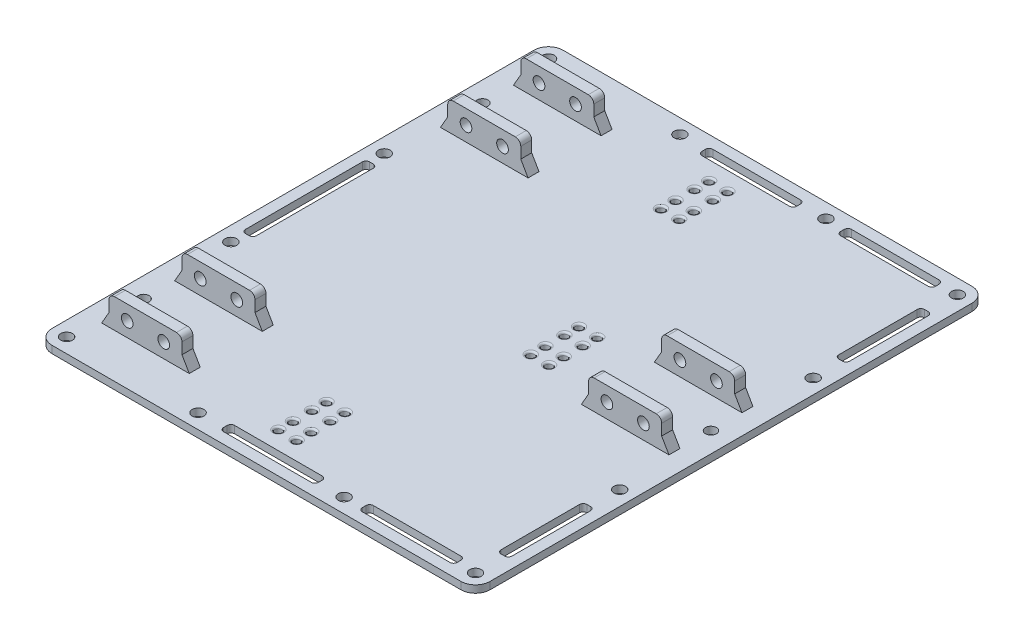
from build123d import *

# Parameters (mm, degrees)
SKETCH1_W           = 120
SKETCH1_H           = 140
BOSS_EXTRUDE1_DEPTH = 2
SKETCH3_W           = 20
SKETCH3_H           = 3
BOSS_EXTRUDE2_DEPTH = 8
SKETCH4_R           = 1.6
CUT_EXTRUDE2_DEPTH  = 142.627716214
SKETCH5_R           = 1.6
CUT_EXTRUDE3_DEPTH  = 93.54188241
FILLET1_R           = 4
SKETCH6_R           = 1
CUT_EXTRUDE4_DEPTH  = 55
CHAMFER1_SIZE       = 2
CHAMFER1_SIZE2      = 3.464101615
CUT_EXTRUDE5_DEPTH  = 93.54188241
FILLET2_R           = 1.5
FILLET3_R           = 0.5
SKETCH9_R           = 1.5
CUT_EXTRUDE6_DEPTH  = 93.54188241


with BuildPart() as part:
    # Sketch1 → Boss-Extrude1 (new body)
    with BuildSketch(Plane(origin=(0, 0, 0), x_dir=(1, 0, 0), z_dir=(0, 1, 0))):
        Rectangle(SKETCH1_W, SKETCH1_H)
    extrude(amount=BOSS_EXTRUDE1_DEPTH)

    # Sketch3 → Boss-Extrude2 (add)
    with BuildSketch(Plane(origin=(0, 2, 0), x_dir=(1, 0, 0), z_dir=(0, 1, 0))):
        with Locations((-42.5, 56.4)):
            Rectangle(SKETCH3_W, SKETCH3_H)
        with Locations((-42.5, 36.4)):
            Rectangle(SKETCH3_W, SKETCH3_H)
        with Locations((-42.5, -36.4)):
            Rectangle(SKETCH3_W, SKETCH3_H)
        with Locations((-42.5, -56.4)):
            Rectangle(SKETCH3_W, SKETCH3_H)
        with Locations((42.5, 10)):
            Rectangle(SKETCH3_W, SKETCH3_H)
        with Locations((42.5, -10)):
            Rectangle(SKETCH3_W, SKETCH3_H)
    extrude(amount=BOSS_EXTRUDE2_DEPTH)

    # Sketch4 → Cut-Extrude2 (cut, through all)
    with BuildSketch(Plane.XY.offset(57.9)):
        with Locations((-47.5, 6)):
            Circle(SKETCH4_R)
        with Locations((-37.5, 6)):
            Circle(SKETCH4_R)
        with Locations((37.5, 6)):
            Circle(SKETCH4_R)
        with Locations((47.5, 6)):
            Circle(SKETCH4_R)
    extrude(amount=-CUT_EXTRUDE2_DEPTH, mode=Mode.SUBTRACT)

    # Sketch5 → Cut-Extrude3 (cut, through all)
    with BuildSketch(Plane(origin=(0, 2, 0), x_dir=(1, 0, 0), z_dir=(0, 1, 0))):
        with Locations((-56, -66)):
            Circle(SKETCH5_R)
        with Locations((56, -66)):
            Circle(SKETCH5_R)
        with Locations((56, 66)):
            Circle(SKETCH5_R)
        with Locations((-56, 66)):
            Circle(SKETCH5_R)
        with Locations((-56, -21)):
            Circle(SKETCH5_R)
        with Locations((-56, 21)):
            Circle(SKETCH5_R)
        with Locations((-20, -66)):
            Circle(SKETCH5_R)
        with Locations((-20, 66)):
            Circle(SKETCH5_R)
        with Locations((20, -66)):
            Circle(SKETCH5_R)
        with Locations((20, 66)):
            Circle(SKETCH5_R)
        with Locations((56, -26.5)):
            Circle(SKETCH5_R)
        with Locations((56, 26.5)):
            Circle(SKETCH5_R)
    extrude(amount=-CUT_EXTRUDE3_DEPTH, mode=Mode.SUBTRACT)

    # Fillet1
    fillet1_edges = [part.edges().sort_by_distance(p)[0] for p in [
        (60, 1, -70),
        (-60, 1, -70),
        (-60, 1, 70),
        (60, 1, 70),
    ]]
    fillet(fillet1_edges, radius=FILLET1_R)

    # Sketch6 → Cut-Extrude4 (cut)
    with BuildSketch(Plane.XZ):
        with Locations((0, 59)):
            Circle(SKETCH6_R)
        with Locations((0, 49.8)):
            Circle(SKETCH6_R)
        with Locations((0, 45.8)):
            Circle(SKETCH6_R)
        with Locations((0, 55)):
            Circle(SKETCH6_R)
        with Locations((0, -49.8)):
            Circle(SKETCH6_R)
        with Locations((0, -55)):
            Circle(SKETCH6_R)
        with Locations((0, -45.8)):
            Circle(SKETCH6_R)
        with Locations((0, -59)):
            Circle(SKETCH6_R)
        with Locations((-5, -49.8)):
            Circle(SKETCH6_R)
        with Locations((-5, -55)):
            Circle(SKETCH6_R)
        with Locations((-5, -45.8)):
            Circle(SKETCH6_R)
        with Locations((-5, -59)):
            Circle(SKETCH6_R)
        with Locations((-5, 59)):
            Circle(SKETCH6_R)
        with Locations((-5, 45.8)):
            Circle(SKETCH6_R)
        with Locations((-5, 55)):
            Circle(SKETCH6_R)
        with Locations((-5, 49.8)):
            Circle(SKETCH6_R)
        with Locations((16.75, 2.6)):
            Circle(SKETCH6_R)
        with Locations((16.75, -2.6)):
            Circle(SKETCH6_R)
        with Locations((16.75, 6.6)):
            Circle(SKETCH6_R)
        with Locations((16.75, -6.6)):
            Circle(SKETCH6_R)
        with Locations((11.75, 2.6)):
            Circle(SKETCH6_R)
        with Locations((11.75, -2.6)):
            Circle(SKETCH6_R)
        with Locations((11.75, 6.6)):
            Circle(SKETCH6_R)
        with Locations((11.75, -6.6)):
            Circle(SKETCH6_R)
    extrude(amount=-CUT_EXTRUDE4_DEPTH, mode=Mode.SUBTRACT)

    # Chamfer1
    chamfer1_edges = [part.edges().sort_by_distance(p)[0] for p in [
        (-32.5, 2, -56.4),
        (-52.5, 2, -56.4),
        (-52.5, 2, -36.4),
        (-32.5, 2, -36.4),
        (52.5, 2, -10),
        (32.5, 2, -10),
        (32.5, 2, 10),
        (52.5, 2, 10),
        (-32.5, 2, 36.4),
        (-52.5, 2, 36.4),
        (-52.5, 2, 56.4),
        (-32.5, 2, 56.4),
    ]]
    chamfer1_side = [part.faces().sort_by_distance(p)[0] for p in [
        (0.299459522, 2, 0),
    ]]
    chamfer(chamfer1_edges, length=CHAMFER1_SIZE, length2=CHAMFER1_SIZE2, reference=chamfer1_side[0])

    # Sketch8 → Cut-Extrude5 (cut, through all)
    with BuildSketch(Plane(origin=(0, 2, 0), x_dir=(1, 0, 0), z_dir=(0, 1, 0))):
        with BuildLine():
            Line((-56, 17), (-55, 17))
            ThreePointArc((-55, 17), (-54.292893219, 16.707106781), (-54, 16))
            Line((-54, 16), (-54, -16))
            ThreePointArc((-54, -16), (-54.292893219, -16.707106781), (-55, -17))
            Line((-55, -17), (-56, -17))
            ThreePointArc((-56, -17), (-56.707106781, -16.707106781), (-57, -16))
            Line((-57, -16), (-57, 16))
            ThreePointArc((-57, 16), (-56.707106781, 16.707106781), (-56, 17))
        make_face()
        with BuildLine():
            Line((-12, -64), (12, -64))
            ThreePointArc((12, -64), (12.707106781, -64.292893219), (13, -65))
            Line((13, -65), (13, -66))
            ThreePointArc((13, -66), (12.707106781, -66.707106781), (12, -67))
            Line((12, -67), (-12, -67))
            ThreePointArc((-12, -67), (-12.707106781, -66.707106781), (-13, -66))
            Line((-13, -66), (-13, -65))
            ThreePointArc((-13, -65), (-12.707106781, -64.292893219), (-12, -64))
        make_face()
        with BuildLine():
            Line((55, -34.5), (56, -34.5))
            ThreePointArc((56, -34.5), (56.707106781, -34.792893219), (57, -35.5))
            Line((57, -35.5), (57, -57))
            ThreePointArc((57, -57), (56.707106781, -57.707106781), (56, -58))
            Line((56, -58), (55, -58))
            ThreePointArc((55, -58), (54.292893219, -57.707106781), (54, -57))
            Line((54, -57), (54, -35.5))
            ThreePointArc((54, -35.5), (54.292893219, -34.792893219), (55, -34.5))
        make_face()
        with BuildLine():
            Line((55, 58), (56, 58))
            ThreePointArc((56, 58), (56.707106781, 57.707106781), (57, 57))
            Line((57, 57), (57, 35.5))
            ThreePointArc((57, 35.5), (56.707106781, 34.792893219), (56, 34.5))
            Line((56, 34.5), (55, 34.5))
            ThreePointArc((55, 34.5), (54.292893219, 34.792893219), (54, 35.5))
            Line((54, 35.5), (54, 57))
            ThreePointArc((54, 57), (54.292893219, 57.707106781), (55, 58))
        make_face()
        with BuildLine():
            Line((26, -64), (50, -64))
            ThreePointArc((50, -64), (50.707106781, -64.292893219), (51, -65))
            Line((51, -65), (51, -66))
            ThreePointArc((51, -66), (50.707106781, -66.707106781), (50, -67))
            Line((50, -67), (26, -67))
            ThreePointArc((26, -67), (25.292893219, -66.707106781), (25, -66))
            Line((25, -66), (25, -65))
            ThreePointArc((25, -65), (25.292893219, -64.292893219), (26, -64))
        make_face()
        with BuildLine():
            Line((51, 65), (51, 66))
            ThreePointArc((51, 66), (50.707106781, 66.707106781), (50, 67))
            Line((50, 67), (26, 67))
            ThreePointArc((26, 67), (25.292893219, 66.707106781), (25, 66))
            Line((25, 66), (25, 65))
            ThreePointArc((25, 65), (25.292893219, 64.292893219), (26, 64))
            Line((26, 64), (50, 64))
            ThreePointArc((50, 64), (50.707106781, 64.292893219), (51, 65))
        make_face()
        with BuildLine():
            Line((13, 65), (13, 66))
            ThreePointArc((13, 66), (12.707106781, 66.707106781), (12, 67))
            Line((12, 67), (-12, 67))
            ThreePointArc((-12, 67), (-12.707106781, 66.707106781), (-13, 66))
            Line((-13, 66), (-13, 65))
            ThreePointArc((-13, 65), (-12.707106781, 64.292893219), (-12, 64))
            Line((-12, 64), (12, 64))
            ThreePointArc((12, 64), (12.707106781, 64.292893219), (13, 65))
        make_face()
    extrude(amount=-CUT_EXTRUDE5_DEPTH, mode=Mode.SUBTRACT)

    # Fillet2
    fillet2_edges = [part.edges().sort_by_distance(p)[0] for p in [
        (52.5, 10, -10),
        (32.5, 10, -10),
        (52.5, 10, 10),
        (32.5, 10, 10),
        (-32.5, 10, -56.4),
        (-52.5, 10, -56.4),
        (-32.5, 10, -36.4),
        (-52.5, 10, -36.4),
        (-32.5, 10, 36.4),
        (-52.5, 10, 36.4),
        (-32.5, 10, 56.4),
        (-52.5, 10, 56.4),
    ]]
    fillet(fillet2_edges, radius=FILLET2_R)

    # Fillet3
    fillet3_edges = [part.edges().sort_by_distance(p)[0] for p in [
        (-6, 2, -59),
        (-1, 2, -59),
        (-1, 2, -55),
        (-6, 2, -55),
        (-6, 2, -49.8),
        (-1, 2, -49.8),
        (-1, 2, -45.8),
        (-6, 2, -45.8),
        (10.75, 2, 6.6),
        (10.75, 2, 2.6),
        (10.75, 2, -2.6),
        (10.75, 2, -6.6),
        (15.75, 2, -6.6),
        (15.75, 2, -2.6),
        (15.75, 2, 2.6),
        (15.75, 2, 6.6),
        (-6, 2, 45.8),
        (-1, 2, 45.8),
        (-1, 2, 49.8),
        (-6, 2, 49.8),
        (-1, 2, 55),
        (-6, 2, 55),
        (-1, 2, 59),
        (-6, 2, 59),
    ]]
    fillet(fillet3_edges, radius=FILLET3_R)

    # Sketch9 → Cut-Extrude6 (cut, through all)
    with BuildSketch(Plane(origin=(0, 2, 0), x_dir=(1, 0, 0), z_dir=(0, 1, 0))):
        with Locations((54.5, 0)):
            Circle(SKETCH9_R)
        with Locations((-54.5, 46.4)):
            Circle(SKETCH9_R)
        with Locations((-54.5, -46.4)):
            Circle(SKETCH9_R)
    extrude(amount=-CUT_EXTRUDE6_DEPTH, mode=Mode.SUBTRACT)


solid = part.part
